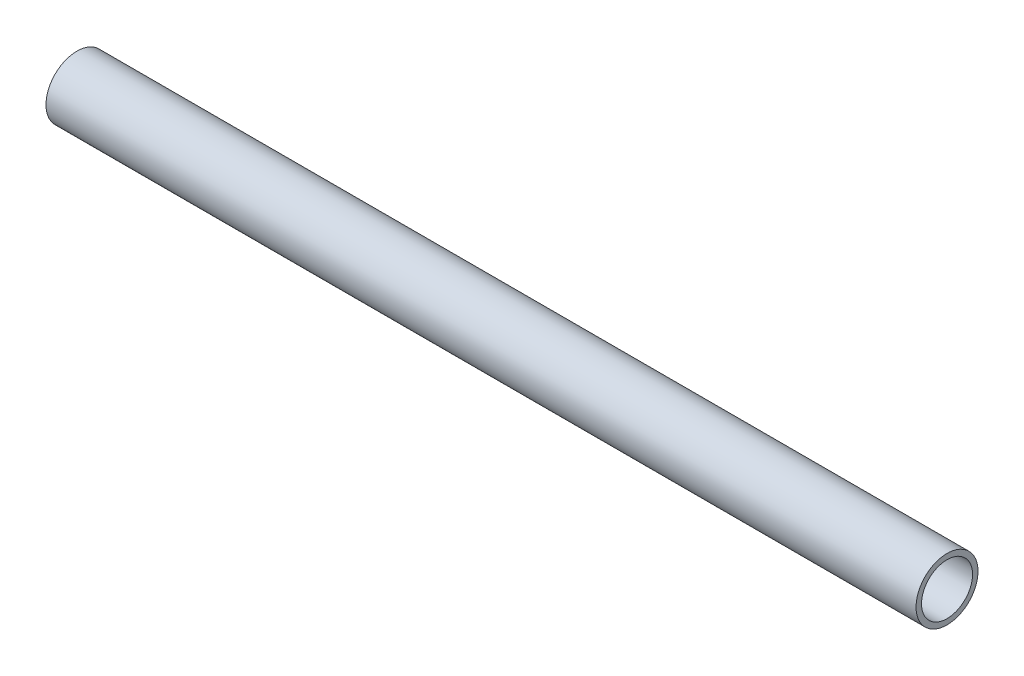
from build123d import *

# Parameters (mm, degrees)
SKETCH1_R               = 3.175
SKETCH1_R_2             = 2.6162
PIPE_0_5_SCH_40_1_DEPTH = 89.157598779


with BuildPart() as part:
    # Sketch1 → Pipe 0.5 SCH 40(1) (new body)
    with BuildSketch(Plane(origin=(-148.488053197, 648.338249624, 0), x_dir=(0, -1, 0), z_dir=(-1, 0, 0))):
        Circle(SKETCH1_R)
        Circle(SKETCH1_R_2, mode=Mode.SUBTRACT)
    extrude(amount=PIPE_0_5_SCH_40_1_DEPTH)


solid = part.part
